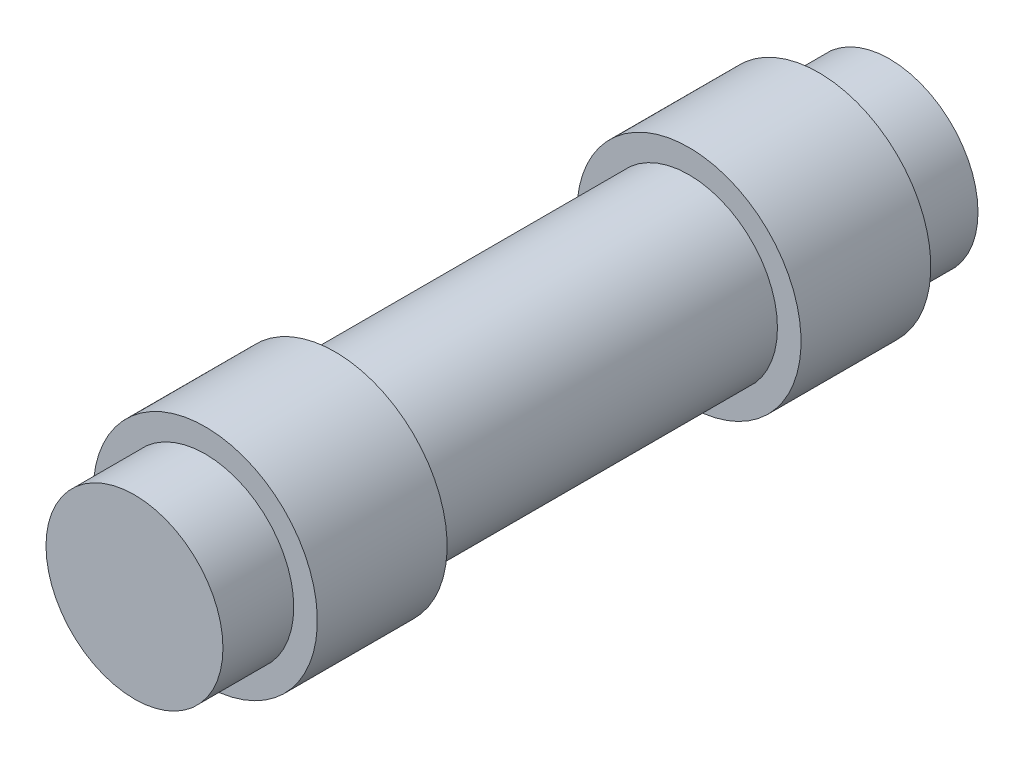
from build123d import *

# Parameters (mm, degrees)
SKETCH1_R           = 3.75
BOSS_EXTRUDE1_DEPTH = 32
SKETCH2_W           = 1
SKETCH2_H           = 5.5


with BuildPart() as part:
    # Sketch1 → Boss-Extrude1 (new body)
    with BuildSketch(Plane.XY):
        Circle(SKETCH1_R)
    extrude(amount=BOSS_EXTRUDE1_DEPTH)

    # Sketch2 → Revolve1 (revolve)
    with BuildSketch(Plane(origin=(0, 0, 0), x_dir=(1, 0, 0), z_dir=(0, 1, 0))):
        with Locations((4.25, -26.25)):
            Rectangle(SKETCH2_W, SKETCH2_H)
        with Locations((4.25, -5.75)):
            Rectangle(SKETCH2_W, SKETCH2_H)
    revolve(axis=Axis((0, 0, 0), (0, 0, 1)))


solid = part.part
